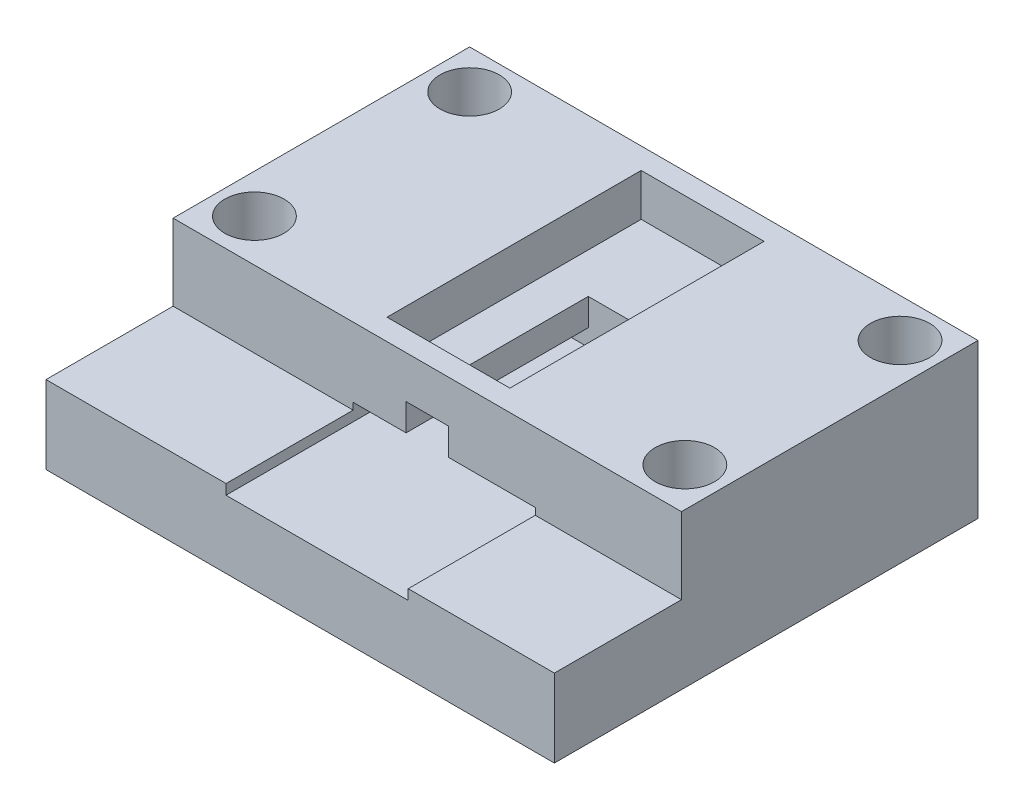
from build123d import *

# Parameters (mm, degrees)
SKETCH2_W               = 60
SKETCH2_H               = 50
BOSS_EXTRUDE1_DEPTH     = 10
SKETCH3_W               = 21.5
SKETCH3_H               = 36.5
CUT_EXTRUDE2_DEPTH      = 2
BOSS_EXTRUDE2_DEPTH     = 3.2
SKETCH5_W               = 60
SKETCH5_H               = 50
SKETCH5_W_2             = 14.5
SKETCH5_H_2             = 30
BOSS_EXTRUDE3_DEPTH     = 5
SKETCH1_R               = 3.5
CUT_EXTRUDE1_DEPTH      = 80.210100366
CUT_EXTRUDE1_DEPTH_BACK = 80.210100366
SKETCH7_W               = 60
SKETCH7_H               = 15
CUT_EXTRUDE3_DEPTH      = 9


with BuildPart() as part:
    # Sketch2 → Boss-Extrude1 (new body)
    with BuildSketch(Plane(origin=(0, 0, 0), x_dir=(1, 0, 0), z_dir=(0, 1, 0))):
        with Locations((30, 25)):
            Rectangle(SKETCH2_W, SKETCH2_H)
    extrude(amount=BOSS_EXTRUDE1_DEPTH)

    # Sketch3 → Cut-Extrude2 (cut)
    with BuildSketch(Plane(origin=(0, 10, 0), x_dir=(1, 0, 0), z_dir=(0, 1, 0))):
        with Locations((32, 18.25)):
            Rectangle(SKETCH3_W, SKETCH3_H)
    extrude(amount=-CUT_EXTRUDE2_DEPTH, mode=Mode.SUBTRACT)

    # Sketch4 → Boss-Extrude2 (add)
    with BuildSketch(Plane(origin=(0, 10, 0), x_dir=(1, 0, 0), z_dir=(0, 1, 0))):
        Polygon((27.5, 0), (27.5, 36.5), (32.5, 36.5), (32.5, 0), (60, 0), (60, 50), (0, 50), (0, 0), align=None)
    extrude(amount=BOSS_EXTRUDE2_DEPTH)

    # Sketch5 → Boss-Extrude3 (add)
    with BuildSketch(Plane(origin=(0, 13.2, 0), x_dir=(1, 0, 0), z_dir=(0, 1, 0))):
        with Locations((30, 25)):
            Rectangle(SKETCH5_W, SKETCH5_H)
        with Locations((30, 32.5)):
            Rectangle(SKETCH5_W_2, SKETCH5_H_2, mode=Mode.SUBTRACT)
    extrude(amount=BOSS_EXTRUDE3_DEPTH)

    # Sketch1 → Cut-Extrude1 (cut, two sides)
    with BuildSketch(Plane(origin=(0, 13.2, 0), x_dir=(1, 0, 0), z_dir=(0, 1, 0))) as cut_extrude1_sk:
        with BuildLine():
            Line((4.6, 48.9), (4.6, 45.4))
            Line((4.6, 45.4), (1.1, 45.4))
            ThreePointArc((1.1, 45.4), (4.6, 41.9), (8.1, 45.4))
            ThreePointArc((8.1, 45.4), (7.074873734, 47.874873734), (4.6, 48.9))
        make_face()
        with BuildLine():
            Line((1.1, 45.4), (4.6, 45.4))
            Line((4.6, 45.4), (4.6, 48.9))
            ThreePointArc((4.6, 48.9), (2.125126266, 47.874873734), (1.1, 45.4))
        make_face()
        with Locations(Location((55.4, 45.4, 0), (0, 0, 270))):
            Circle(SKETCH1_R)
        with Locations(Location((4.6, 20, 0), (0, 0, 270))):
            Circle(SKETCH1_R)
        with Locations(Location((55.4, 20, 0), (0, 0, 270))):
            Circle(SKETCH1_R)
    extrude(amount=CUT_EXTRUDE1_DEPTH, mode=Mode.SUBTRACT)
    extrude(cut_extrude1_sk.sketch, amount=-CUT_EXTRUDE1_DEPTH_BACK, mode=Mode.SUBTRACT)

    # Sketch7 → Cut-Extrude3 (cut)
    with BuildSketch(Plane(origin=(0, 18.2, 0), x_dir=(1, 0, 0), z_dir=(0, 1, 0))):
        with Locations((30, 7.5)):
            Rectangle(SKETCH7_W, SKETCH7_H)
    extrude(amount=-CUT_EXTRUDE3_DEPTH, mode=Mode.SUBTRACT)


solid = part.part
